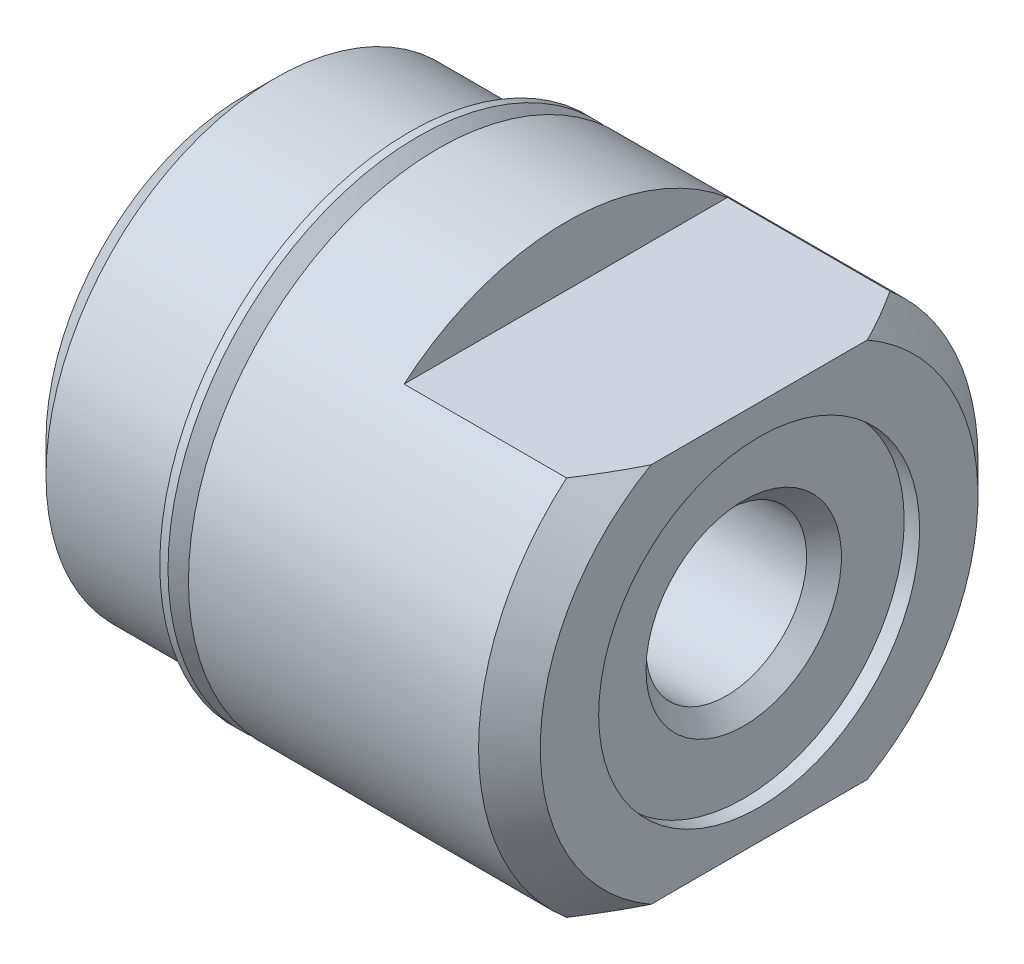
from build123d import *

# Parameters (mm, degrees)
SKETCH2_W          = 0.381
SKETCH2_H          = 3.9624
SKETCH4_W          = 49.3268
SKETCH4_H          = 24.6634
SKETCH4_W_2        = 24.6634
SKETCH4_H_2        = 9.398
CUT_EXTRUDE1_DEPTH = 4.7752


with BuildPart() as part:
    # Sketch1 → Revolve1 (revolve)
    with BuildSketch(Plane.XY):
        Polygon((0, 0), (0, 4.90855), (0.762, 5.67055), (3.7592, 5.67055), (4.2672, 5.16255), (4.7752, 5.16255), (4.7752, 6.16585), (11.938, 6.16585), (12.7, 5.40385), (12.7, 0), align=None)
    revolve(axis=Axis((12.7, 0, 0), (-1, 0, 0)))

    # Sketch2 → Cut-Revolve1 (revolve, cut)
    with BuildSketch(Plane.XY):
        with Locations((12.5095, 1.9812)):
            Rectangle(SKETCH2_W, SKETCH2_H)
    revolve(axis=Axis((12.7, 0, 0), (-1, 0, 0)), mode=Mode.SUBTRACT)

    # Sketch3 → Cut-Revolve2 (revolve, cut)
    with BuildSketch(Plane.XY):
        Polygon((0, 0), (0, 1.98374), (11.88974, 1.98374), (12.319, 2.413), (12.319, 0), align=None)
    revolve(axis=Axis((12.319, 0, 0), (-1, 0, 0)), mode=Mode.SUBTRACT)

    # Sketch4 → Cut-Extrude1 (cut)
    with BuildSketch(Plane(origin=(12.7, 0, 0), x_dir=(0, 0, -1), z_dir=(1, 0, 0))):
        Rectangle(SKETCH4_W, SKETCH4_H)
        Rectangle(SKETCH4_W_2, SKETCH4_H_2, mode=Mode.SUBTRACT)
    extrude(amount=-CUT_EXTRUDE1_DEPTH, mode=Mode.SUBTRACT)

    # Sketch5 → Revolve2 (revolve)
    with BuildSketch(Plane.XY):
        with BuildLine():
            Line((4.066488686, 6.16585), (4.066488686, 6.081681804))
            Line((4.066488686, 6.081681804), (4.663607684, 5.484562806))
            ThreePointArc((4.663607684, 5.484562806), (4.700805122, 5.394760245), (4.663607684, 5.304957684))
            Line((4.663607684, 5.304957684), (4.5212, 5.16255))
            Line((4.5212, 5.16255), (4.2672, 5.16255))
            Line((4.2672, 5.16255), (4.2672, 4.90855))
            Line((4.2672, 4.90855), (4.7752, 4.90855))
            Line((4.7752, 4.90855), (4.7752, 5.660338686))
            Line((4.7752, 5.660338686), (4.269688686, 6.16585))
            Line((4.269688686, 6.16585), (4.066488686, 6.16585))
        make_face()
    revolve(axis=Axis((4.7752, 0, 0), (-1, 0, 0)))


solid = part.part
